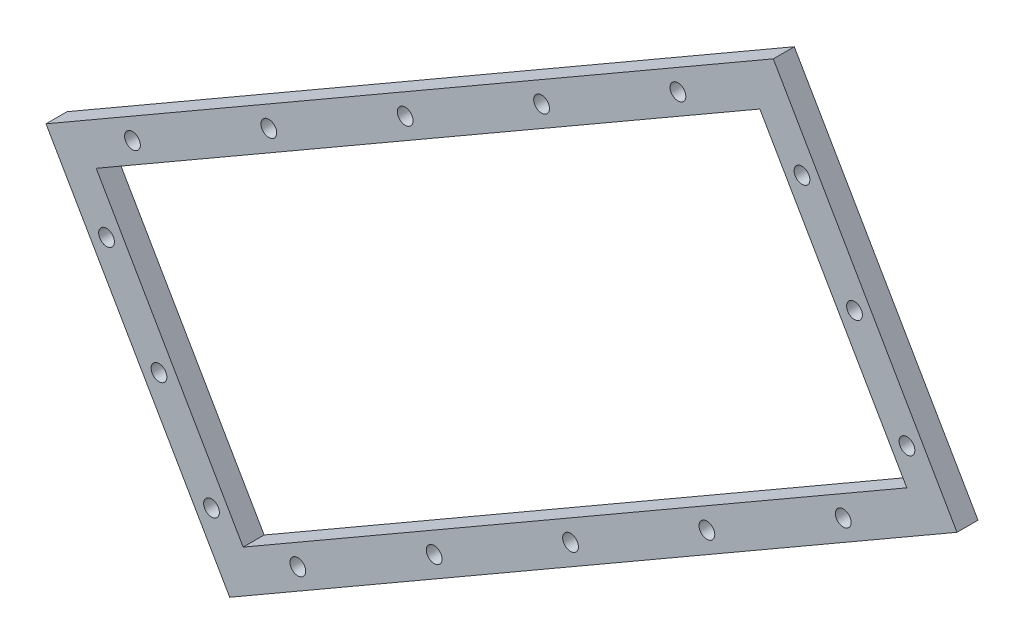
from build123d import *

# Parameters (mm, degrees)
SKETCH_1_R           = 1.5
SKETCH_1_R_2         = 69.25
EXTRUDE_1_DEPTH      = 3
SKETCH_2_R           = 1.5
CUT_EXTRUDE_1_DEPTH  = 10
EXTRUDE_4_DEPTH      = 30
SKETCH_21_R          = 1.5
CUT_EXTRUDE_16_DEPTH = 264.511765735
SKETCH_22_R          = 1.5
CUT_EXTRUDE_17_DEPTH = 15
EXTRUDE_5_DEPTH      = 13
SKETCH_25_R          = 1.5
CUT_EXTRUDE_18_DEPTH = 8
SKETCH_26_R          = 1.5
CUT_EXTRUDE_19_DEPTH = 265
EXTRUDE_6_DEPTH      = 10
CUT_EXTRUDE_20_DEPTH = 265
EXTRUDE_8_DEPTH      = 10
SKETCH_31_R          = 1.5
CUT_EXTRUDE_22_DEPTH = 265
SKETCH_32_W          = 406.044805538
SKETCH_32_H          = 345.897022528
CUT_EXTRUDE_23_DEPTH = 265
CUT_EXTRUDE_24_DEPTH = 79
SKETCH_34_W          = 228.886402988
SKETCH_34_H          = 166.453973012
CUT_EXTRUDE_25_DEPTH = 6


with BuildPart() as part:
    # Sketch 1 → Extrude 1 (new body)
    with BuildSketch(Plane.XY):
        with BuildLine():
            Line((-22.769302312, -105.521905889), (96.897661611, -36.432152055))
            Line((96.897661611, -36.432152055), (159.096032483, -0.521905889))
            ThreePointArc((159.096032483, -0.521905889), (163.755290746, 5.550157697), (162.756286521, 13.138348148))
            Line((162.756286521, 13.138348148), (92.756286521, 134.381904678))
            ThreePointArc((92.756286521, 134.381904678), (86.684222934, 139.041162941), (79.096032483, 138.042158716))
            Line((79.096032483, 138.042158716), (16.897661611, 102.13191255))
            Line((16.897661611, 102.13191255), (-102.769302312, 33.042158716))
            ThreePointArc((-102.769302312, 33.042158716), (-133.627927222, -77.150119753), (-22.769302312, -105.521905889))
        make_face()
        with Locations((0, 74.563800918)):
            Circle(SKETCH_1_R, mode=Mode.SUBTRACT)
        with Locations((64.574145798, -37.281900459)):
            Circle(SKETCH_1_R, mode=Mode.SUBTRACT)
        with Locations((-64.574145798, -37.281900459)):
            Circle(SKETCH_1_R, mode=Mode.SUBTRACT)
        Circle(SKETCH_1_R_2, mode=Mode.SUBTRACT)
    extrude(amount=EXTRUDE_1_DEPTH)

    # Sketch 2 → Cut-Extrude 1 (cut)
    with BuildSketch(Plane(origin=(0, 0, 0), x_dir=(-1, 0, 0), z_dir=(0, 0, -1))):
        with Locations((-109.955016331, 4.59283082)):
            Circle(SKETCH_2_R)
        with Locations((-130.739626022, 16.59283082)):
            Circle(SKETCH_2_R)
        with Locations((-58.955016331, 92.927422006)):
            Circle(SKETCH_2_R)
        with Locations((-79.739626022, 104.927422006)):
            Circle(SKETCH_2_R)
    extrude(amount=-CUT_EXTRUDE_1_DEPTH, mode=Mode.SUBTRACT)

    # Sketch 20 → Extrude 4 (add)
    with BuildSketch(Plane(origin=(0, 0, 0), x_dir=(-1, 0, 0), z_dir=(0, 0, -1))):
        with BuildLine():
            Line((-92.756286521, 134.381904678), (-162.756286521, 13.138348148))
            ThreePointArc((-162.756286521, 13.138348148), (-163.755290746, 5.550157697), (-159.096032483, -0.521905889))
            Line((-159.096032483, -0.521905889), (22.769302312, -105.521905889))
            ThreePointArc((22.769302312, -105.521905889), (133.627927222, -77.150119753), (102.769302312, 33.042158716))
            Line((102.769302312, 33.042158716), (-79.096032483, 138.042158716))
            ThreePointArc((-79.096032483, 138.042158716), (-86.684222934, 139.041162941), (-92.756286521, 134.381904678))
        make_face()
        with BuildLine():
            Line((-89.292184905, 132.381904678), (-159.292184905, 11.138348148))
            ThreePointArc((-159.292184905, 11.138348148), (-159.89158744, 6.585433878), (-157.096032483, 2.942195726))
            Line((-157.096032483, 2.942195726), (24.808773358, -102.080592893))
            ThreePointArc((24.808773358, -102.080592893), (130.163825607, -75.150119753), (100.808773358, 29.555268482))
            Line((100.808773358, 29.555268482), (-81.096032483, 134.578057101))
            ThreePointArc((-81.096032483, 134.578057101), (-85.648946753, 135.177459636), (-89.292184905, 132.381904678))
        make_face(mode=Mode.SUBTRACT)
    extrude(amount=EXTRUDE_4_DEPTH)

    # Sketch 21 → Cut-Extrude 16 (cut, through all)
    with BuildSketch(Plane(origin=(-40, 69.282032303, 0), x_dir=(0.866025404, 0.5, 0), z_dir=(-0.5, 0.866025404, 0))):
        with Locations((-62.479747173, 25)):
            Circle(SKETCH_21_R)
        with Locations((-32.479747173, 25)):
            Circle(SKETCH_21_R)
        with Locations((-2.479747173, 25)):
            Circle(SKETCH_21_R)
        with Locations((27.520252827, 25)):
            Circle(SKETCH_21_R)
        with Locations((57.520252827, 25)):
            Circle(SKETCH_21_R)
        with Locations((87.520252827, 25)):
            Circle(SKETCH_21_R)
        with Locations((117.520252827, 25)):
            Circle(SKETCH_21_R)
    extrude(amount=-CUT_EXTRUDE_16_DEPTH, mode=Mode.SUBTRACT)

    # Sketch 22 → Cut-Extrude 17 (cut)
    with BuildSketch(Plane(origin=(127.756286521, 73.760126413, 0), x_dir=(0, 0, -1), z_dir=(0.866025404, 0.5, 0))):
        with Locations((25, 60)):
            Circle(SKETCH_22_R)
        with Locations((25, 30)):
            Circle(SKETCH_22_R)
        with Locations((25, 0)):
            Circle(SKETCH_22_R)
        with Locations((25, -30)):
            Circle(SKETCH_22_R)
        with Locations((25, -60)):
            Circle(SKETCH_22_R)
    extrude(amount=-CUT_EXTRUDE_17_DEPTH, mode=Mode.SUBTRACT)

    # Sketch 23 → Extrude 5 (add)
    with BuildSketch(Plane(origin=(0, 0, 0), x_dir=(-1, 0, 0), z_dir=(0, 0, -1))):
        with BuildLine():
            Line((100.710773859, 29.380908411), (-81.196032483, 134.40485202))
            ThreePointArc((-81.196032483, 134.40485202), (-85.597182944, 134.984274471), (-89.118979825, 132.281904678))
            Line((-89.118979825, 132.281904678), (-159.118979825, 11.038348148))
            ThreePointArc((-159.118979825, 11.038348148), (-159.698402275, 6.637197687), (-156.996032483, 3.115400806))
            Line((-156.996032483, 3.115400806), (24.910773859, -101.908542802))
            ThreePointArc((24.910773859, -101.908542802), (129.990620526, -75.050119753), (100.710773859, 29.380908411))
        make_face()
        with BuildLine():
            Line((98.261672903, 25.021394816), (-83.696032483, 130.074725001))
            ThreePointArc((-83.696032483, 130.074725001), (-84.303087719, 130.154645339), (-84.788852806, 129.781904678))
            Line((-84.788852806, 129.781904678), (-154.788852806, 8.538348148))
            ThreePointArc((-154.788852806, 8.538348148), (-154.868773144, 7.931292912), (-154.496032483, 7.445527825))
            Line((-154.496032483, 7.445527825), (27.461672903, -97.60780236))
            ThreePointArc((27.461672903, -97.60780236), (125.660493508, -72.550119753), (98.261672903, 25.021394816))
        make_face(mode=Mode.SUBTRACT)
    extrude(amount=-EXTRUDE_5_DEPTH)

    # Sketch 25 → Cut-Extrude 18 (cut)
    with BuildSketch(Plane(origin=(124.118979825, 71.660126413, 0), x_dir=(0, 0, -1), z_dir=(0.866025404, 0.5, 0))):
        with Locations((-8, 60)):
            Circle(SKETCH_25_R)
        with Locations((-8, 30)):
            Circle(SKETCH_25_R)
        with Locations((-8, 0)):
            Circle(SKETCH_25_R)
        with Locations((-8, -30)):
            Circle(SKETCH_25_R)
        with Locations((-8, -60)):
            Circle(SKETCH_25_R)
    extrude(amount=-CUT_EXTRUDE_18_DEPTH, mode=Mode.SUBTRACT)

    # Sketch 26 → Cut-Extrude 19 (cut)
    with BuildSketch(Plane(origin=(-37.9, 65.644725607, 0), x_dir=(0.866025404, 0.5, 0), z_dir=(-0.5, 0.866025404, 0))):
        with Locations((-62.479747173, -8)):
            Circle(SKETCH_26_R)
        with Locations((-32.479747173, -8)):
            Circle(SKETCH_26_R)
        with Locations((-2.479747173, -8)):
            Circle(SKETCH_26_R)
        with Locations((27.520252827, -8)):
            Circle(SKETCH_26_R)
        with Locations((57.520252827, -8)):
            Circle(SKETCH_26_R)
        with Locations((87.520252827, -8)):
            Circle(SKETCH_26_R)
        with Locations((117.520252827, -8)):
            Circle(SKETCH_26_R)
    extrude(amount=-CUT_EXTRUDE_19_DEPTH, mode=Mode.SUBTRACT)

    # Sketch 27 → Extrude 6 (add)
    with BuildSketch(Plane.XY.offset(3)):
        Polygon((-45.361672903, -66.604092905), (93.202391703, 13.395907095), (58.202391703, 74.01768536), (-80.361672903, -5.98231464), align=None)
        Polygon((55.640213876, 64.455507534), (83.640213876, 15.958084922), (-42.799495076, -57.041915078), (-70.799495076, -8.544492466), align=None, mode=Mode.SUBTRACT)
    extrude(amount=EXTRUDE_6_DEPTH)

    # Sketch 28 → Cut-Extrude 20 (cut)
    with BuildSketch(Plane.XY.offset(13)):
        Polygon((-15.72564869, -92.217646268), (-14.42564869, -94.469312318), (-19.275390952, -97.269312318), (-20.575390952, -95.017646268), align=None)
        Polygon((6.705371162, -82.269312318), (11.555113423, -79.469312318), (10.255113423, -77.217646268), (5.405371162, -80.017646268), align=None)
        Polygon((32.686133275, -67.269312318), (37.535875537, -64.469312318), (36.235875537, -62.217646268), (31.386133275, -65.017646268), align=None)
        Polygon((58.666895389, -52.269312318), (63.51663765, -49.469312318), (62.21663765, -47.217646268), (57.366895389, -50.017646268), align=None)
        Polygon((84.647657503, -37.269312318), (89.497399764, -34.469312318), (88.197399764, -32.217646268), (83.347657503, -35.017646268), align=None)
        Polygon((110.628419616, -22.269312318), (115.478161877, -19.469312318), (114.178161877, -17.217646268), (109.328419616, -20.017646268), align=None)
        Polygon((136.60918173, -7.269312318), (141.458923991, -4.469312318), (140.158923991, -2.217646268), (135.30918173, -5.017646268), align=None)
        Polygon((63.30918173, 119.690011877), (62.00918173, 121.941677927), (66.858923991, 124.741677927), (68.158923991, 122.490011877), align=None)
        Polygon((37.328419616, 104.690011877), (36.028419616, 106.941677927), (40.878161877, 109.741677927), (42.178161877, 107.490011877), align=None)
        Polygon((11.347657503, 89.690011877), (10.047657503, 91.941677927), (14.897399764, 94.741677927), (16.197399764, 92.490011877), align=None)
        Polygon((-14.633104611, 74.690011877), (-15.933104611, 76.941677927), (-11.08336235, 79.741677927), (-9.78336235, 77.490011877), align=None)
        Polygon((-40.613866724, 59.690011877), (-41.913866724, 61.941677927), (-37.064124463, 64.741677927), (-35.764124463, 62.490011877), align=None)
        Polygon((-93.875390952, 31.941677927), (-89.02564869, 34.741677927), (-87.72564869, 32.490011877), (-92.575390952, 29.690011877), align=None)
        Polygon((-66.594628838, 44.690011877), (-67.894628838, 46.941677927), (-63.044886577, 49.741677927), (-61.744886577, 47.490011877), align=None)
        Polygon((149.42808329, 20.223473317), (152.22808329, 15.373731056), (154.47974934, 16.673731056), (151.67974934, 21.523473317), align=None)
        Polygon((139.47974934, 42.654493169), (136.67974934, 47.50423543), (134.42808329, 46.20423543), (137.22808329, 41.354493169), align=None)
        Polygon((124.47974934, 68.635255283), (121.67974934, 73.484997544), (119.42808329, 72.184997544), (122.22808329, 67.335255283), align=None)
        Polygon((109.47974934, 94.616017396), (106.67974934, 99.465759657), (104.42808329, 98.165759657), (107.22808329, 93.316017396), align=None)
        Polygon((94.47974934, 120.59677951), (91.67974934, 125.446521771), (89.42808329, 124.146521771), (92.22808329, 119.29677951), align=None)
    extrude(amount=-CUT_EXTRUDE_20_DEPTH, mode=Mode.SUBTRACT)

    # Sketch 30 → Extrude 8 (add)
    with BuildSketch(Plane.XY.offset(13)):
        Polygon((112.068054668, 85.310371985), (107.922916101, 89.712531664), (68.135584713, 52.248192829), (71.241913135, 46.867874176), align=None)
        Polygon((98.950505999, 108.394899743), (96.406644359, 113.779322647), (59.34542331, 66.089123081), (62.213357562, 61.121715243), align=None)
        Polygon((24.331505485, 98.768362958), (19.708497886, 96.891947732), (53.142901297, 66.089123081), (55.972189919, 69.160126413), align=None)
        Polygon((2.949445409, 86.456661235), (0, 84.758307493), (1.655787903, 38.106211971), (7.724521177, 40.569427371), align=None)
        Polygon((-1.747976688, 36.718440517), (-50.523677842, 57.700122779), (-54.943097479, 51.790017141), (-9.512673828, 32.247361853), align=None)
        Polygon((-45.889743184, 10.259239907), (-76.964412717, 39.337819671), (-81.650646335, 36.718440517), (-50.523677842, 7.590921232), align=None)
        Polygon((-73.350083184, -11.065799194), (-73.350083184, -5.618546996), (-120.801864013, 8.92508057), (-124.763106008, 4.691920389), align=None)
        Polygon((-66.087162089, -25.245346168), (-69.124877332, -21.644521246), (-136.839384074, -34.709590506), (-136.839384074, -42.002122059), align=None)
        Polygon((-53.307143918, -49.04163918), (-54.906692153, -44.610488149), (-104.794596754, -97.505321817), (-98.479079171, -101.151587593), align=None)
        Polygon((-41.540846023, -60.713761909), (-46.258304807, -57.99013581), (-58.318230755, -110.393979453), (-52.671585502, -109.080023344), align=None)
        Polygon((-18.687908296, -47.55024912), (-9.026220892, -89.07075422), (-4.414655194, -86.322046436), (-14.060109209, -44.871303324), align=None)
        Polygon((23.170697656, -24.36189812), (17.379921767, -73.477126749), (24.707933207, -72.604849894), (30.925113931, -19.873012476), align=None)
        Polygon((73.402847471, -42.379153747), (76.34838766, -40.674035966), (38.996415308, -13.595082114), (33.82884156, -17.619151598), align=None)
        Polygon((93.765137101, -31.377914027), (97.701664154, -28.312479616), (87.880521362, 13.893275169), (83.80631015, 12.978541014), align=None)
        Polygon((146.739106017, 26.600941785), (143.347989818, 31.496202041), (84.039636905, 23.317490482), (86.907571157, 18.350082644), align=None)
        Polygon((131.65478951, 48.607721162), (129.91497668, 54.398596303), (76.209726226, 38.263369501), (79.316054648, 32.883050848), align=None)
    extrude(amount=-EXTRUDE_8_DEPTH)

    # Sketch 31 → Cut-Extrude 22 (cut)
    with BuildSketch(Plane.XY.offset(13)):
        with Locations((-63.889241039, -0.513403553)):
            Circle(SKETCH_31_R)
        with Locations((-37.908478925, 14.486596447)):
            Circle(SKETCH_31_R)
        with Locations((-11.927716811, 29.486596447)):
            Circle(SKETCH_31_R)
        with Locations((14.053045302, 44.486596447)):
            Circle(SKETCH_31_R)
        with Locations((40.033807416, 59.486596447)):
            Circle(SKETCH_31_R)
        with Locations((-68.83058399, -18.954746504)):
            Circle(SKETCH_31_R)
        with Locations((-58.83058399, -36.27525458)):
            Circle(SKETCH_31_R)
        with Locations((-48.83058399, -53.595762655)):
            Circle(SKETCH_31_R)
        with Locations((83.671302789, 22.904237345)):
            Circle(SKETCH_31_R)
        with Locations((73.671302789, 40.22474542)):
            Circle(SKETCH_31_R)
        with Locations((63.671302789, 57.545253496)):
            Circle(SKETCH_31_R)
        with Locations((71.533807416, 4.926996009)):
            Circle(SKETCH_31_R)
        with Locations((45.553045302, -10.073003991)):
            Circle(SKETCH_31_R)
        with Locations((19.572283189, -25.073003991)):
            Circle(SKETCH_31_R)
        with Locations((-6.408478925, -40.073003991)):
            Circle(SKETCH_31_R)
        with Locations((-32.389241038, -55.073003991)):
            Circle(SKETCH_31_R)
    extrude(amount=-CUT_EXTRUDE_22_DEPTH, mode=Mode.SUBTRACT)

    # Sketch 32 → Cut-Extrude 23 (cut)
    with BuildSketch(Plane.XY.offset(3)):
        Rectangle(SKETCH_32_W, SKETCH_32_H)
    extrude(amount=-CUT_EXTRUDE_23_DEPTH, mode=Mode.SUBTRACT)

    # Sketch 33 → Cut-Extrude 24 (cut)
    with BuildSketch(Plane.XY.offset(13)):
        Polygon((639.612553216, -133.014254418), (169.771470014, -404.277130281), (-191.771834417, -613.014254418), (-397.136779793, -257.311734934), (-421.406889041, -215.274672611), (-626.771834417, 140.427846874), (-265.228529986, 349.164971011), (204.612553216, 620.427846874), align=None)
        Polygon((-65.228529986, 2.754809497), (-80.361672903, -5.98231464), (-74.996727527, -15.274672611), (-50.726618279, -57.311734934), (-45.361672903, -66.604092905), (-30.228529986, -57.866968768), (93.202391703, 13.395907095), (58.202391703, 74.01768536), align=None, mode=Mode.SUBTRACT)
    extrude(amount=-CUT_EXTRUDE_24_DEPTH, mode=Mode.SUBTRACT)

    # Sketch 34 → Cut-Extrude 25 (cut)
    with BuildSketch(Plane.XY.offset(13)):
        Rectangle(SKETCH_34_W, SKETCH_34_H)
    extrude(amount=-CUT_EXTRUDE_25_DEPTH, mode=Mode.SUBTRACT)


solid = part.part
